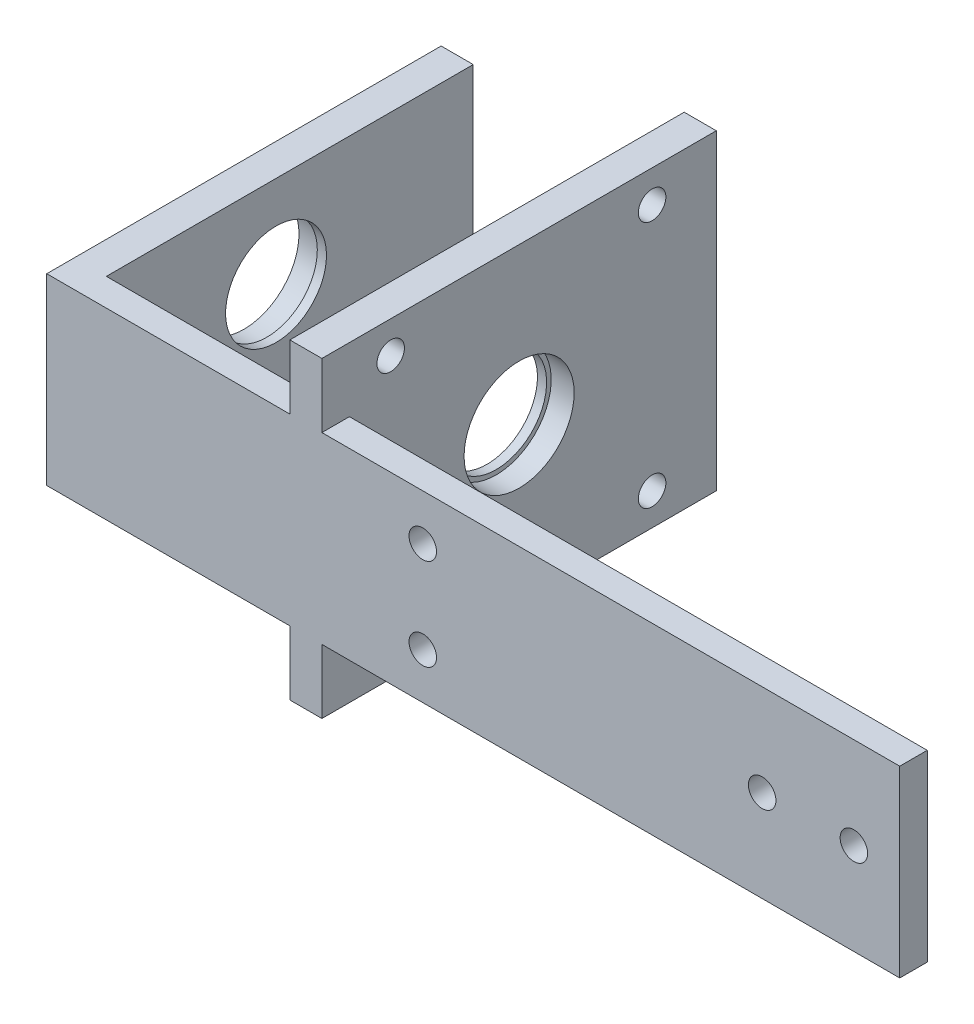
from build123d import *

# Parameters (mm, degrees)
SKETCH_1_R          = 1.5
EXTRUDE_1_DEPTH     = 3
EXTRUDE_2_DEPTH     = 40
SKETCH_2_R          = 1.5
CUT_EXTRUDE_1_DEPTH = 10
SKETCH_1_4_W        = 3.5
SKETCH_1_4_H        = 20
EXTRUDE_3_DEPTH     = 40
SKETCH_3_R          = 6
CUT_EXTRUDE_2_DEPTH = 38
SKETCH_4_R          = 6
SKETCH_4_R_2        = 5.5
EXTRUDE_4_DEPTH     = 1
EXTRUDE_START       = -1
SKETCH_5_R          = 6
SKETCH_5_R_2        = 5.5
EXTRUDE_5_DEPTH     = 1
SKETCH_7_R          = 1.5
CUT_EXTRUDE_4_DEPTH = 5


with BuildPart() as part:
    # 草图1 → 凸台-拉伸1 (new body)
    with BuildSketch(Plane.XY):
        Polygon((10, 9.854248689), (-53, 9.854248689), (-53, 16.854248689), (-56.5, 16.854248689), (-56.5, 9.854248689), (-83, 9.854248689), (-83, -10.145751311), (-56.5, -10.145751311), (-56.5, -17.145751311), (-53, -17.145751311), (-53, -10.145751311), (10, -10.145751311), align=None)
        with Locations((-5, -0.145751311)):
            Circle(SKETCH_1_R, mode=Mode.SUBTRACT)
        with Locations((5, -0.145751311)):
            Circle(SKETCH_1_R, mode=Mode.SUBTRACT)
    extrude(amount=EXTRUDE_1_DEPTH)

    # 草图1<3> → 凸台-拉伸2 (add)
    with BuildSketch(Plane.XY):
        Polygon((-56.5, 16.854248689), (-56.5, 9.854248689), (-56.5, -10.145751311), (-56.5, -17.145751311), (-53, -17.145751311), (-53, -0.145751311), (-53, 16.854248689), align=None)
    extrude(amount=-EXTRUDE_2_DEPTH)

    # 草图2 → 切除-拉伸1 (cut, symmetric)
    with BuildSketch(Plane(origin=(-53, 0, 0), x_dir=(0, 0, -1), z_dir=(-1, 0, 0))):
        with Locations((33, -13.354248689)):
            Circle(SKETCH_2_R)
        with Locations((4.5, 13.645751311)):
            Circle(SKETCH_2_R)
        with Locations((33, 13.645751311)):
            Circle(SKETCH_2_R)
        with Locations((4.5, -13.354248689)):
            Circle(SKETCH_2_R)
    extrude(amount=CUT_EXTRUDE_1_DEPTH, both=True, mode=Mode.SUBTRACT)

    # 草图1<4> → 凸台-拉伸3 (add)
    with BuildSketch(Plane.XY):
        with Locations((-81.25, -0.145751311)):
            Rectangle(SKETCH_1_4_W, SKETCH_1_4_H)
    extrude(amount=-EXTRUDE_3_DEPTH)

    # 草图3 → 切除-拉伸2 (cut)
    with BuildSketch(Plane.ZY.offset(83)):
        with Locations((-18.5, -0.145751311)):
            Circle(SKETCH_3_R)
    extrude(amount=-CUT_EXTRUDE_2_DEPTH, mode=Mode.SUBTRACT)

    # 草图4 → 凸台-拉伸4 (add)
    with BuildSketch(Plane.ZY.offset(56.5)):
        with Locations((-18.5, -0.145751311)):
            Circle(SKETCH_4_R)
        with Locations((-18.5, -0.145751311)):
            Circle(SKETCH_4_R_2, mode=Mode.SUBTRACT)
    extrude(amount=-EXTRUDE_4_DEPTH)

    # 草图5 → 凸台-拉伸5 (add)
    with BuildSketch(Plane(origin=(-79.5, 0, 0), x_dir=(0, 0, -1), z_dir=(1, 0, 0)).offset(EXTRUDE_START)):
        with Locations((18.5, -0.145751311)):
            Circle(SKETCH_5_R)
        with Locations((18.5, -0.145751311)):
            Circle(SKETCH_5_R_2, mode=Mode.SUBTRACT)
    extrude(amount=EXTRUDE_5_DEPTH)

    # 草图7 → 切除-拉伸4 (cut)
    with BuildSketch(Plane.XY.offset(3)):
        with Locations((-42, -5.146051054)):
            Circle(SKETCH_7_R)
        with Locations((-42, 4.853948946)):
            Circle(SKETCH_7_R)
    extrude(amount=-CUT_EXTRUDE_4_DEPTH, mode=Mode.SUBTRACT)


solid = part.part
